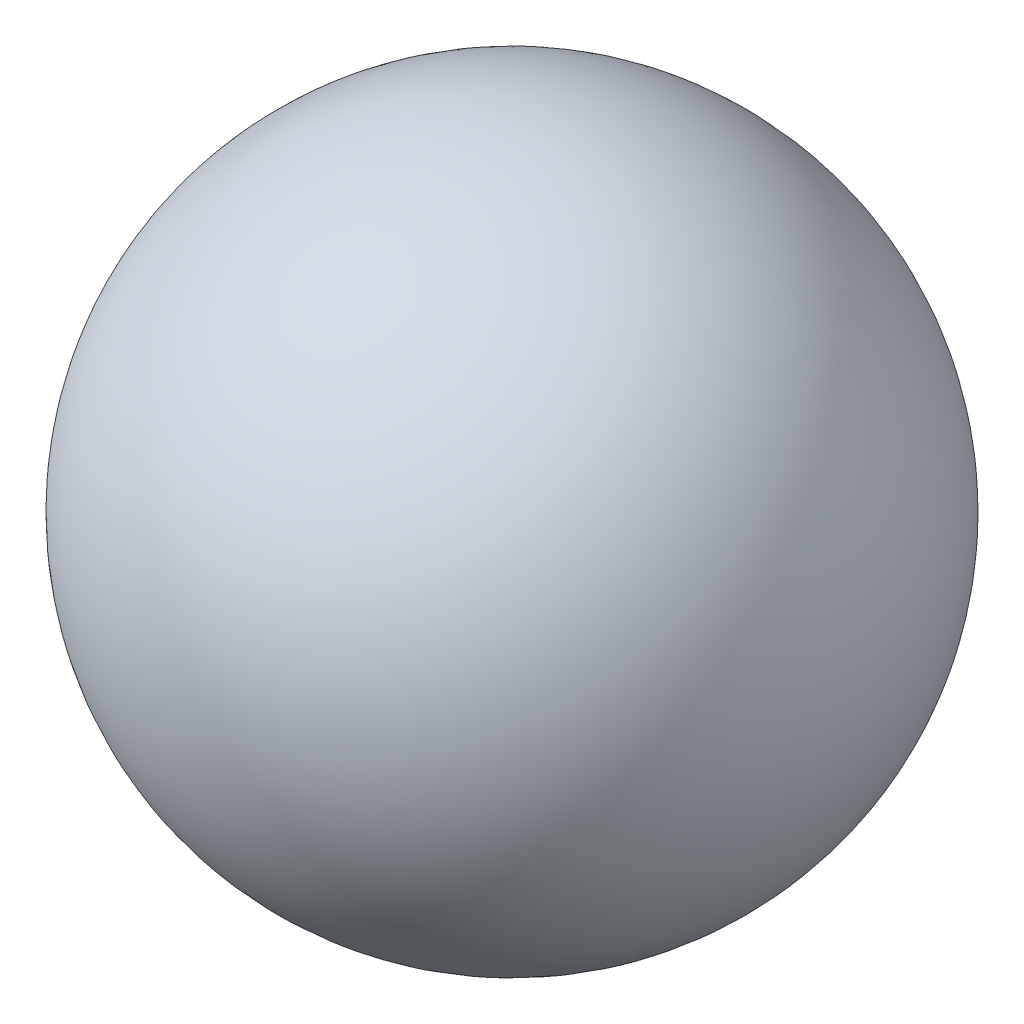
from build123d import *


with BuildPart() as part:
    # Эскиз3 → Revolve 152 (revolve)
    with BuildSketch(Plane.XY):
        with BuildLine():
            Line((-600, 0), (600, 0))
            add(Edge.make_bspline(
                [(600, 0), (600, 600), (0, 600), (-600, 600), (-600, 0)],
                knots=[1.570796327, 1.570796327, 1.570796327, 3.141592654, 3.141592654, 4.71238898, 4.71238898, 4.71238898], degree=2, weights=[1, 0.707106781, 1, 0.707106781, 1]))
        make_face()
    revolve(axis=Axis((-2000, 0, 0), (1, 0, 0)))


solid = part.part
